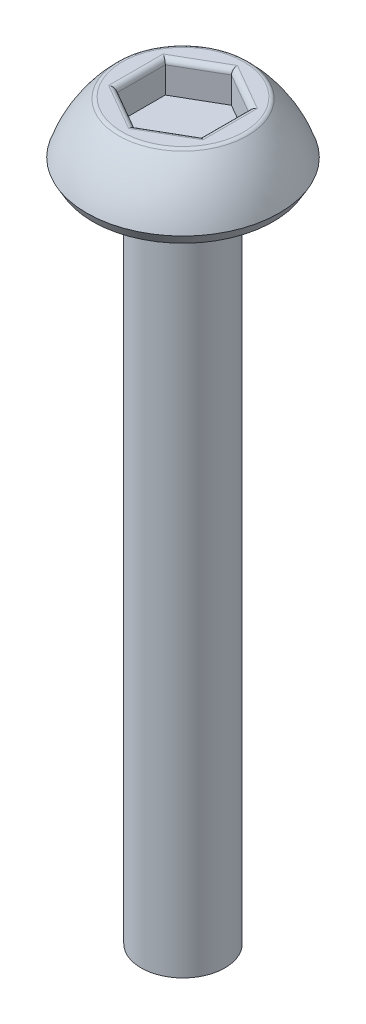
from build123d import *

# Parameters (mm, degrees)
CUT_EXTRUDE1_DEPTH = 0.75
FILLET1_R          = 0.125


with BuildPart() as part:
    # Sketch1 → Revolve1 (revolve)
    with BuildSketch(Plane(origin=(0, 0, 0), x_dir=(0, 0, -1), z_dir=(1, 0, 0))):
        with BuildLine():
            Line((0, 1.5), (-1.5, 1.5))
            ThreePointArc((-1.5, 1.5), (-1.978515811, 0.925250119), (-2.3, 0.25))
            Line((-2.3, 0.25), (-2.155662433, 0))
            Line((-2.155662433, 0), (-1, 0))
            Line((-1, 0), (-1, -16))
            Line((-1, -16), (0, -16))
            Line((0, -16), (0, 1.5))
        make_face()
    revolve(axis=Axis((0, -16, 0), (0, 1, 0)))

    # Sketch2 → Cut-Extrude1 (cut)
    with BuildSketch(Plane(origin=(0, 1.5, 0), x_dir=(1, 0, 0), z_dir=(0, 1, 0))):
        Polygon((0, 1.154700538), (-1, 0.577350269), (-1, -0.577350269), (0, -1.154700538), (1, -0.577350269), (1, 0.577350269), align=None)
    extrude(amount=-CUT_EXTRUDE1_DEPTH, mode=Mode.SUBTRACT)

    # Fillet1
    fillet1_edges = [part.edges().sort_by_distance(p)[0] for p in [
        (0.5, 1.5, -0.866025404),
        (-0.5, 1.5, -0.866025404),
        (-1, 1.5, 0),
        (-0.5, 1.5, 0.866025404),
        (0.5, 1.5, 0.866025404),
        (1, 1.5, 0),
        (0, 1.5, -1.5),
    ]]
    fillet(fillet1_edges, radius=FILLET1_R)


solid = part.part
